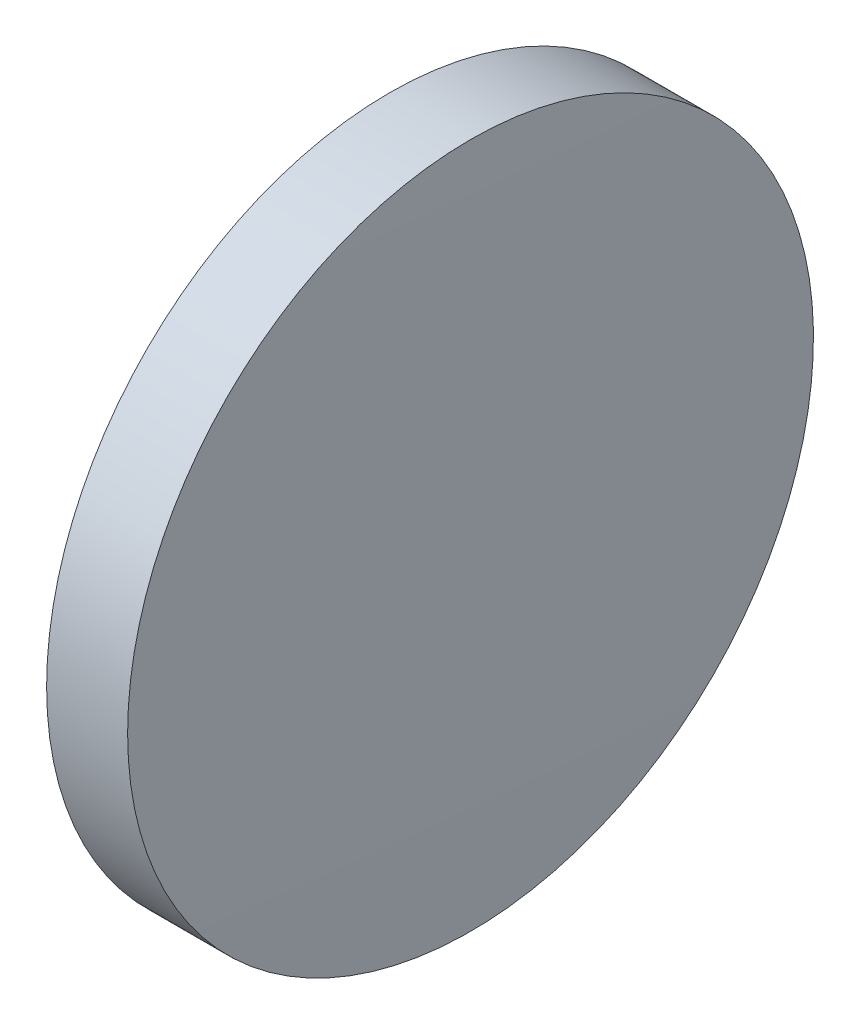
from build123d import *

# Parameters (mm, degrees)
SKETCH_1_ONE_SIDE_W = 2.999957714
SKETCH_1_ONE_SIDE_H = 12.7


with BuildPart() as part:
    # 草图1 one side → 旋转1 (revolve)
    with BuildSketch(Plane.XY):
        with Locations((86.458193775, 54.966113023)):
            Rectangle(SKETCH_1_ONE_SIDE_W, SKETCH_1_ONE_SIDE_H)
        with BuildLine():
            Line((84.848196632, 48.616113023), (84.958214918, 48.616113023))
            Line((84.958214918, 48.616113023), (84.958214918, 61.316113023))
            ThreePointArc((84.958214918, 61.316113023), (84.875701719, 54.966351287), (84.848196632, 48.616113023))
        make_face()
        with BuildLine():
            Line((87.958172632, 48.616113023), (88.068190918, 48.616113023))
            ThreePointArc((88.068190918, 48.616113023), (88.04068583, 54.966351287), (87.958172632, 61.316113023))
            Line((87.958172632, 61.316113023), (87.958172632, 48.616113023))
        make_face()
    revolve(axis=Axis((83.371981052, 48.616113023, 0), (1, 0, 0)))


solid = part.part
